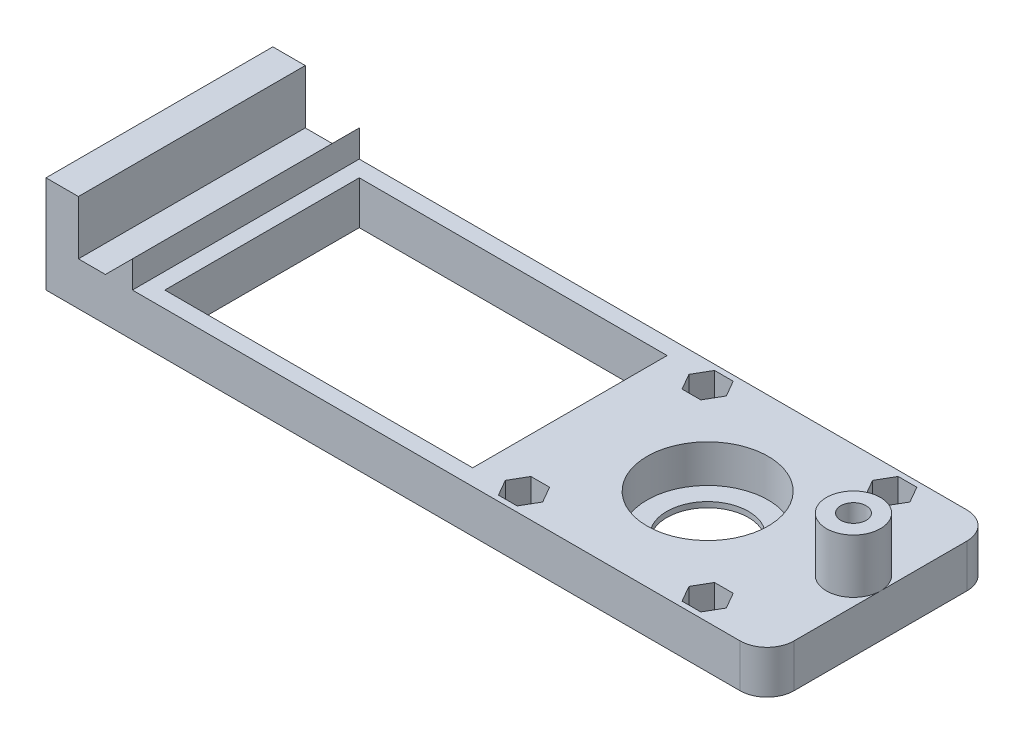
from build123d import *

# Parameters (mm, degrees)
SKETCH1_W           = 123.5
SKETCH1_H           = 42
BOSS_EXTRUDE1_DEPTH = 8
SKETCH2_R           = 11.2
CUT_EXTRUDE1_DEPTH  = 7
CUT_EXTRUDE2_REACH  = 10
SKETCH3_R           = 7.55
CUT_EXTRUDE4_DEPTH  = 6
SKETCH10_R          = 1.75
CUT_EXTRUDE5_DEPTH  = 2
SKETCH12_W          = 6
SKETCH12_H          = 10
BOSS_EXTRUDE2_DEPTH = 42
SKETCH13_W          = 57
SKETCH13_H          = 36
CUT_EXTRUDE6_DEPTH  = 9
SKETCH23_W          = 10
SKETCH23_H          = 42
BOSS_EXTRUDE3_DEPTH = 8
SKETCH24_R          = 5
BOSS_EXTRUDE4_DEPTH = 10
FILLET1_R           = 5
SKETCH25_R          = 2.35
CUT_EXTRUDE7_DEPTH  = 18


with BuildPart() as part:
    # Sketch1 → Boss-Extrude1 (new body)
    with BuildSketch(Plane(origin=(0, 0, 0), x_dir=(1, 0, 0), z_dir=(0, 1, 0))):
        Rectangle(SKETCH1_W, SKETCH1_H)
    extrude(amount=BOSS_EXTRUDE1_DEPTH)

    # Sketch2 → Cut-Extrude1 (cut)
    with BuildSketch(Plane(origin=(0, 8, 0), x_dir=(1, 0, 0), z_dir=(0, 1, 0))):
        with Locations((39.75, 0)):
            Circle(SKETCH2_R)
    extrude(amount=-CUT_EXTRUDE1_DEPTH, mode=Mode.SUBTRACT)

    # Sketch3 → Cut-Extrude2 (cut, up to next)
    with BuildSketch(Plane.XZ, mode=Mode.PRIVATE) as cut_extrude2_sk1:
        with Locations((39.75, 0)):
            Circle(SKETCH3_R)
    cut_extrude2_tool1 = extrude(cut_extrude2_sk1.sketch, amount=-CUT_EXTRUDE2_REACH, mode=Mode.PRIVATE) & part.part
    add(cut_extrude2_tool1.solids().sort_by_distance((39.75, 0, 0))[0], mode=Mode.SUBTRACT)

    # Sketch9 → Cut-Extrude4 (cut)
    with BuildSketch(Plane(origin=(0, 8, 0), x_dir=(1, 0, 0), z_dir=(0, 1, 0))):
        Polygon((58.482050808, 20), (55.017949192, 20), (53.285898385, 17), (55.017949192, 14), (58.482050808, 14), (60.214101615, 17), align=None)
        Polygon((60.214101615, -17), (58.482050808, -20), (55.017949192, -20), (53.285898385, -17), (55.017949192, -14), (58.482050808, -14), align=None)
        Polygon((19.285898385, 17), (21.017949192, 20), (24.482050808, 20), (26.214101615, 17), (24.482050808, 14), (21.017949192, 14), align=None)
        Polygon((21.017949192, -14), (19.285898385, -17), (21.017949192, -20), (24.482050808, -20), (26.214101615, -17), (24.482050808, -14), align=None)
    extrude(amount=-CUT_EXTRUDE4_DEPTH, mode=Mode.SUBTRACT)

    # Sketch10 → Cut-Extrude5 (cut)
    with BuildSketch(Plane.XZ):
        with Locations((56.75, 17)):
            Circle(SKETCH10_R)
        with Locations((22.75, 17)):
            Circle(SKETCH10_R)
        with Locations((56.75, -17)):
            Circle(SKETCH10_R)
        with Locations((22.75, -17)):
            Circle(SKETCH10_R)
    extrude(amount=-CUT_EXTRUDE5_DEPTH, mode=Mode.SUBTRACT)

    # Sketch12 → Boss-Extrude2 (add)
    with BuildSketch(Plane(origin=(0, 0, -21), x_dir=(-1, 0, 0), z_dir=(0, 0, -1))):
        with Locations((58.75, 13)):
            Rectangle(SKETCH12_W, SKETCH12_H)
        Polygon((50.75, 8), (45.75, 8), (45.75, 13), align=None)
    extrude(amount=-BOSS_EXTRUDE2_DEPTH)

    # Sketch13 → Cut-Extrude6 (cut, through all)
    with BuildSketch(Plane(origin=(0, 8, 0), x_dir=(1, 0, 0), z_dir=(0, 1, 0))):
        with Locations((-14.25, 0)):
            Rectangle(SKETCH13_W, SKETCH13_H)
    extrude(amount=-CUT_EXTRUDE6_DEPTH, mode=Mode.SUBTRACT)

    # Sketch23 → Boss-Extrude3 (add)
    with BuildSketch(Plane(origin=(0, 8, 0), x_dir=(1, 0, 0), z_dir=(0, 1, 0))):
        with Locations((66.75, 0)):
            Rectangle(SKETCH23_W, SKETCH23_H)
    extrude(amount=-BOSS_EXTRUDE3_DEPTH)

    # Sketch24 → Boss-Extrude4 (add)
    with BuildSketch(Plane(origin=(0, 8, 0), x_dir=(1, 0, 0), z_dir=(0, 1, 0))):
        with Locations((66.75, 0)):
            Circle(SKETCH24_R)
    extrude(amount=BOSS_EXTRUDE4_DEPTH)

    # Fillet1
    fillet1_edges = [part.edges().sort_by_distance(p)[0] for p in [
        (71.75, 4, -21),
        (71.75, 4, 21),
    ]]
    fillet(fillet1_edges, radius=FILLET1_R)

    # Sketch25 → Cut-Extrude7 (cut)
    with BuildSketch(Plane(origin=(0, 18, 0), x_dir=(1, 0, 0), z_dir=(0, 1, 0))):
        with Locations((66.75, 0)):
            Circle(SKETCH25_R)
    extrude(amount=-CUT_EXTRUDE7_DEPTH, mode=Mode.SUBTRACT)


solid = part.part
